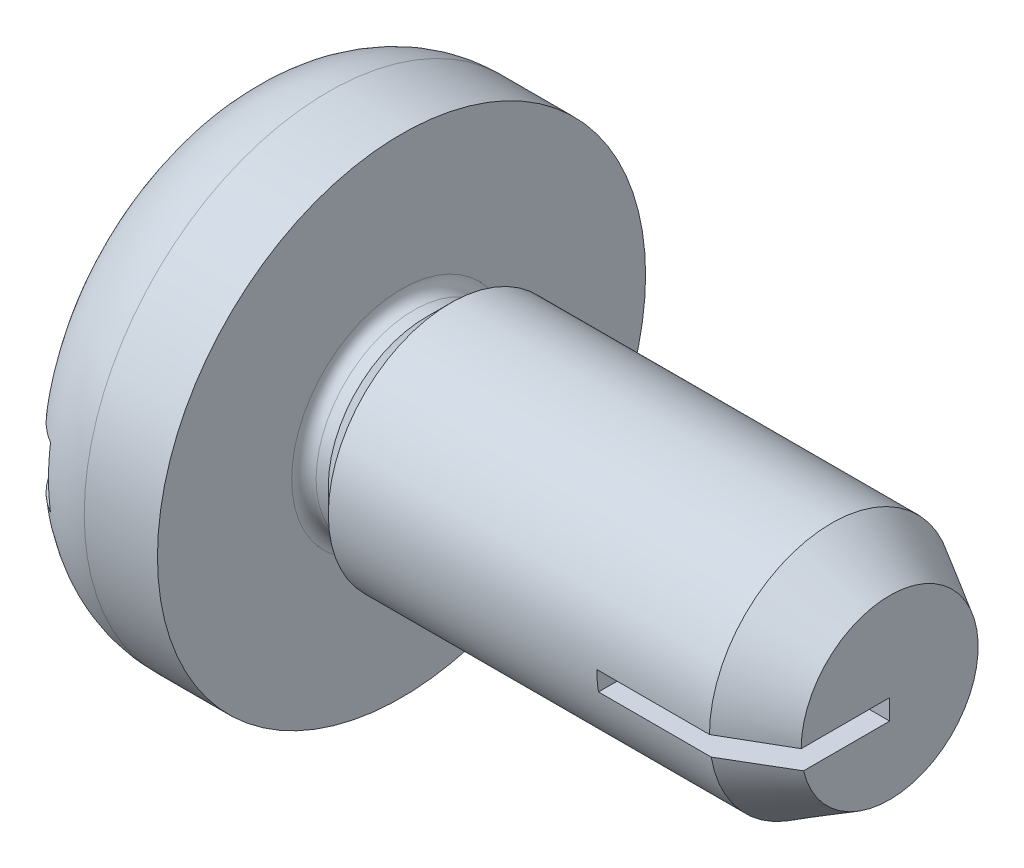
from build123d import *

# Parameters (mm, degrees)
SKETCH2_W                    = 0.4
SKETCH2_H                    = 0.5
SLOT_CUT_EXTRUDE1_DEPTH      = 3
SLOT_CUT_EXTRUDE1_DEPTH_BACK = 3
SKETCH11_W                   = 1.4
SKETCH11_H                   = 0.166666667
POINT_CUT_EXTRUDE8_DEPTH     = 3.0000001


with BuildPart() as part:
    # Sketch1 → base-Revolve (revolve)
    with BuildSketch(Plane.XY):
        with BuildLine():
            Line((0, 0), (0, 1.2))
            ThreePointArc((0, 1.2), (0.234314575, 1.765685425), (0.8, 2))
            Line((0.8, 2), (1.4, 2))
            Line((1.4, 2), (1.4, 0.9))
            ThreePointArc((1.4, 0.9), (1.429289322, 0.829289322), (1.5, 0.8))
            Line((1.5, 0.8), (1.6, 0.8))
            Line((1.6, 0.8), (1.8, 1))
            Line((1.8, 1), (5.4, 1))
            Line((5.4, 1), (5.4, 0))
            Line((5.4, 0), (0, 0))
        make_face()
    revolve(axis=Axis((0, 0, 0), (1, 0, 0)))

    # Sketch2 → slot_Cut-Extrude1 (cut, two sides)
    with BuildSketch(Plane.XY) as slot_cut_extrude1_sk:
        with Locations((0.2, 0)):
            Rectangle(SKETCH2_W, SKETCH2_H)
    extrude(amount=SLOT_CUT_EXTRUDE1_DEPTH, mode=Mode.SUBTRACT)
    extrude(slot_cut_extrude1_sk.sketch, amount=-SLOT_CUT_EXTRUDE1_DEPTH_BACK, mode=Mode.SUBTRACT)

    # Sketch8 → point_Cut-Revolve1 (revolve, cut)
    with BuildSketch(Plane.XY):
        Polygon((5.4, 0), (5.908, 0), (5.908, 1.508), (4.923686028, 1.508), (4.923686028, 1), (5.4, 0.725), align=None)
    revolve(axis=Axis((0, 0, 0), (1, 0, 0)), mode=Mode.SUBTRACT)

    # Sketch11 → point_Cut-Extrude8 (cut, through all)
    with BuildSketch(Plane.XY):
        with Locations((4.7, -0.083333334)):
            Rectangle(SKETCH11_W, SKETCH11_H)
    extrude(amount=POINT_CUT_EXTRUDE8_DEPTH, mode=Mode.SUBTRACT)


solid = part.part
